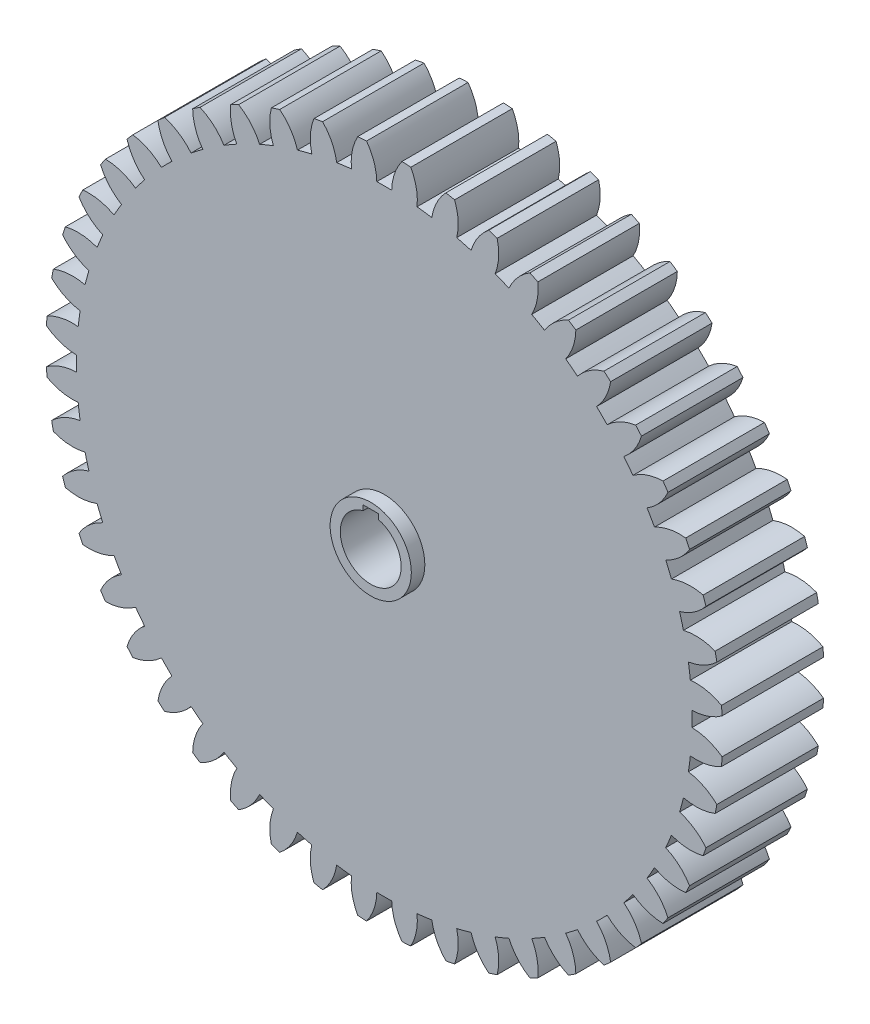
from build123d import *

# Parameters (mm, degrees)
SKETCH2_R               = 50
BOSS_EXTRUDE1_DEPTH     = 7.5
CUT_EXTRUDE1_DEPTH      = 8.5
SKETCH4_R               = 6
BOSS_EXTRUDE2_DEPTH     = 2
CUT_EXTRUDE7_DEPTH      = 3
CUT_EXTRUDE7_DEPTH_BACK = 18
CIRPATTERN1_COUNT       = 48


with BuildPart() as part:
    # Sketch2 → Boss-Extrude1 (new body, symmetric)
    with BuildSketch(Plane.XY):
        Circle(SKETCH2_R)
    extrude(amount=BOSS_EXTRUDE1_DEPTH, both=True)

    # Sketch3 → Cut-Extrude1 (cut, symmetric)
    with BuildSketch(Plane.XY):
        with BuildLine():
            ThreePointArc((-2.617806339, 49.931423873), (-1.518056431, 47.825520361), (-1.100783842, 45.486682391))
            ThreePointArc((-1.100783842, 45.486682391), (0, 45.5), (1.100783842, 45.486682391))
            ThreePointArc((1.100783842, 45.486682391), (1.518056431, 47.825520361), (2.617806339, 49.931423873))
            ThreePointArc((2.617806339, 49.931423873), (0, 50), (-2.617806339, 49.931423873))
        make_face()
    cut_extrude1 = extrude(amount=CUT_EXTRUDE1_DEPTH, both=True, mode=Mode.SUBTRACT)

    # Sketch4 → Boss-Extrude2 (add)
    with BuildSketch(Plane.XY.offset(7.5)):
        Circle(SKETCH4_R)
        with BuildLine():
            ThreePointArc((1.125, 4.357106264), (0, -4.5), (-1.125, 4.357106264))
            Line((-1.125, 4.357106264), (-1.125, 5.107106264))
            Line((-1.125, 5.107106264), (1.125, 5.107106264))
            Line((1.125, 5.107106264), (1.125, 4.357106264))
        make_face(mode=Mode.SUBTRACT)
    boss_extrude2 = extrude(amount=BOSS_EXTRUDE2_DEPTH)

    # Mirror1: Boss-Extrude2 across plane
    add(boss_extrude2.mirror(Plane.XY))

    # Sketch5 → Cut-Extrude7 (cut, two sides)
    with BuildSketch(Plane.XY.offset(7.5)) as cut_extrude7_sk:
        with BuildLine():
            Line((1.125, 4.357106264), (1.125, 5.107106264))
            Line((1.125, 5.107106264), (-1.125, 5.107106264))
            Line((-1.125, 5.107106264), (-1.125, 4.357106264))
            ThreePointArc((-1.125, 4.357106264), (0, -4.5), (1.125, 4.357106264))
        make_face()
    extrude(amount=CUT_EXTRUDE7_DEPTH, mode=Mode.SUBTRACT)
    extrude(cut_extrude7_sk.sketch, amount=-CUT_EXTRUDE7_DEPTH_BACK, mode=Mode.SUBTRACT)

    # CirPattern1: Cut-Extrude1 ×48 about axis
    cirpattern1_axis = Axis((0, 0, 0), (0, 0, 1))
    for i in range(1, CIRPATTERN1_COUNT):
        add(cut_extrude1.rotate(cirpattern1_axis, i * 360 / CIRPATTERN1_COUNT), mode=Mode.SUBTRACT)


solid = part.part
